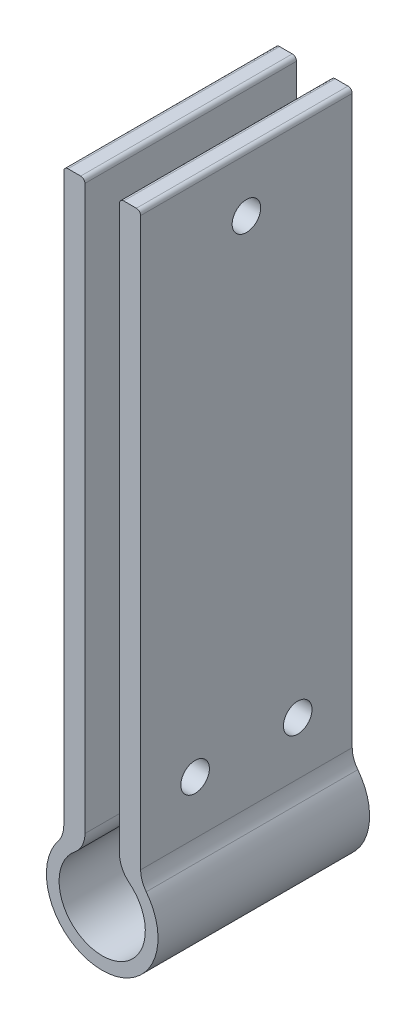
from build123d import *

# Parameters (mm, degrees)
BOSS_EXTRU_1_DEPTH = 40
CONG_1_R           = 5
CONG_2_R           = 0.8
D_GAGEMENT_M1_61_D = 5.4


with BuildPart() as part:
    # Esquisse1 → Boss.-Extru.1 (new body)
    with BuildSketch(Plane.XY):
        with BuildLine():
            Line((-3.266012474, 7.466971442), (-3.266012474, 117.466971442))
            Line((-3.266012474, 117.466971442), (-7.266012474, 117.466971442))
            Line((-7.266012474, 117.466971442), (-7.266012474, 7.649023646))
            ThreePointArc((-7.266012474, 7.649023646), (0, -10.55), (7.266012474, 7.649023646))
            Line((7.266012474, 7.649023646), (7.266012474, 117.466971442))
            Line((7.266012474, 117.466971442), (3.266012474, 117.466971442))
            Line((3.266012474, 117.466971442), (3.266012474, 7.466971442))
            ThreePointArc((3.266012474, 7.466971442), (0, -8.15), (-3.266012474, 7.466971442))
        make_face()
    extrude(amount=BOSS_EXTRU_1_DEPTH)

    # Congé1
    cong_1_edges = [part.edges().sort_by_distance(p)[0] for p in [
        (7.266012474, 7.649023646, 20),
        (-7.266012474, 7.649023646, 20),
        (-3.266012474, 7.466971442, 20),
        (3.266012474, 7.466971442, 20),
    ]]
    fillet(cong_1_edges, radius=CONG_1_R)

    # Congé2
    cong_2_edges = [part.edges().sort_by_distance(p)[0] for p in [
        (3.266012474, 117.466971442, 20),
        (7.266012474, 117.466971442, 20),
        (-7.266012474, 117.466971442, 20),
        (-3.266012474, 117.466971442, 20),
    ]]
    fillet(cong_2_edges, radius=CONG_2_R)

    # Dégagement M1.61 (through all)
    with Locations(Plane.ZY.offset(7.266012474)):
        with Locations((20, 106.594477776), (10.299577014, 19.622753657), (29.700422986, 19.622753657)):
            Hole(D_GAGEMENT_M1_61_D / 2)


solid = part.part
